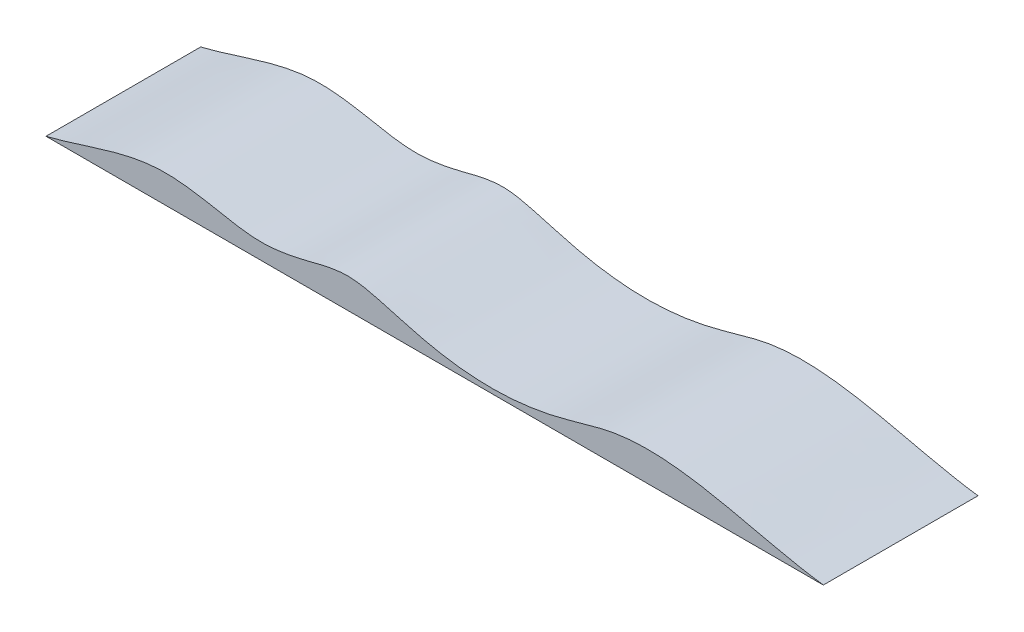
from build123d import *

# Parameters (mm, degrees)
EXTRUDE_2_DEPTH = 125


with BuildPart() as part:
    # 草图1 → 凸台-拉伸2 (new body, symmetric)
    with BuildSketch(Plane.XY):
        with BuildLine():
            Line((-275.27818408, -25.783042496), (981.04880688, -25.783042496))
            add(Edge.make_bspline(
                [(-275.27818408, -25.783042496), (-214.842189299, -11.304422447), (-126.437229666, 29.852619909), (-8.989675912, 12.278838897), (68.985431184, -5.342719709), (143.445044402, 8.810527131), (206.934674698, 27.715282674), (270.543218903, 12.979700321), (345.303429457, -10.141685603), (444.099083616, -23.030114611), (548.256173339, -9.590322373), (721.212653194, 50.380434936), (872.026456766, -11.265860376), (981.04880688, -25.783042496)],
                knots=[0, 0, 0, 0, 0.150155666, 0.213515857, 0.276280052, 0.335933585, 0.389672279, 0.428665547, 0.486345427, 0.574789701, 0.659788448, 0.731421321, 1, 1, 1, 1], degree=3))
        make_face()
    extrude(amount=EXTRUDE_2_DEPTH, both=True)


solid = part.part
